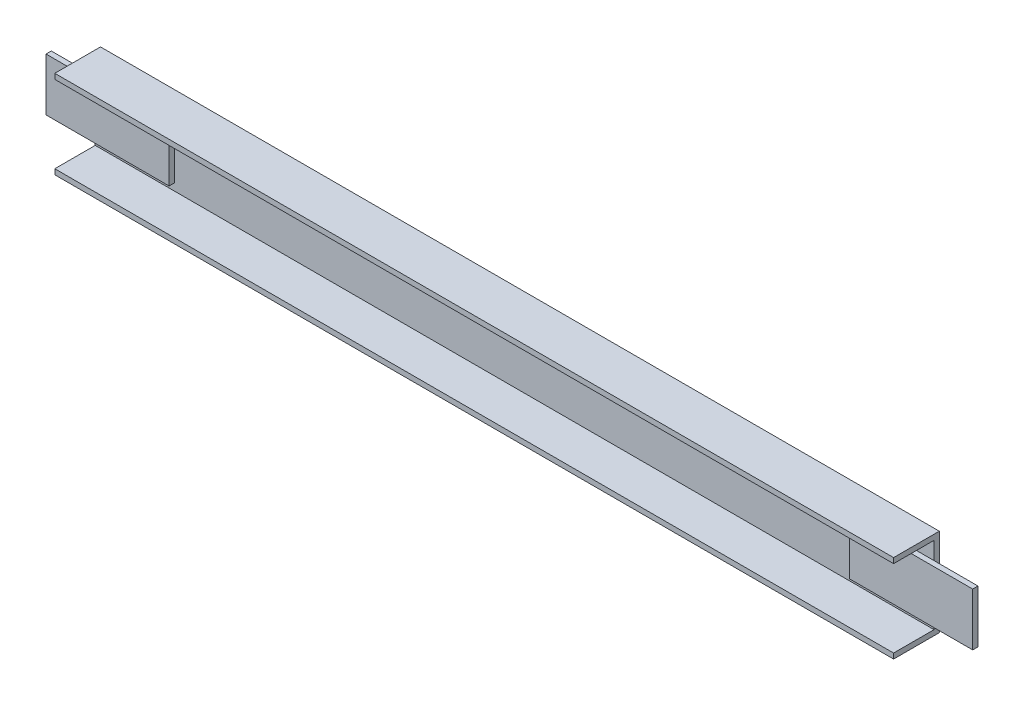
from build123d import *

# Parameters (mm, degrees)
SKETCH1_W           = 477.000009268
SKETCH1_H           = 50.00000447
BOSS_EXTRUDE1_DEPTH = 25.999993086
SKETCH2_W           = 23.000001907
SKETCH2_H           = 43.999992311
CUT_EXTRUDE1_DEPTH  = 722.543490013
SKETCH3_W           = 99.999994039
SKETCH3_H           = 30.000001192
BOSS_EXTRUDE2_DEPTH = 2.999991179
SKETCH4_W           = 99.999995902
SKETCH4_H           = 30.000001192
BOSS_EXTRUDE3_DEPTH = 2.999991179
SKETCH5_W           = 19.999995828
SKETCH5_H           = 19.999995828
BOSS_EXTRUDE4_DEPTH = 10.000020266
MOVE_FACE8_BY       = 30
MOVE_FACE8_2_BY     = 30
MOVE_FACE9_BY       = 5
MOVE_FACE9_2_BY     = 5
MOVE_FACE10_BY      = 5
MOVE_FACE10_2_BY    = 5
MOVE_FACE11_BY      = 2
MOVE_FACE11_2_BY    = 2
MOVE_FACE12_BY      = 2
MOVE_FACE12_2_BY    = 2


with BuildPart() as part:
    # Sketch1 → Boss-Extrude1 (new body)
    with BuildSketch(Plane.XY.offset(513.999998569)):
        with Locations((177.500003949, 144.999999553)):
            Rectangle(SKETCH1_W, SKETCH1_H)
    extrude(amount=-BOSS_EXTRUDE1_DEPTH)

    # Sketch2 → Cut-Extrude1 (cut, through all)
    with BuildSketch(Plane.ZY.offset(61.000000685)):
        with Locations((502.499997616, 144.999999553)):
            Rectangle(SKETCH2_W, SKETCH2_H)
    extrude(amount=-CUT_EXTRUDE1_DEPTH, mode=Mode.SUBTRACT)

    # Sketch3 → Boss-Extrude2 (add)
    with BuildSketch(Plane.XY.offset(490.999996662)):
        with Locations((420.999988914, 144.999995828)):
            Rectangle(SKETCH3_W, SKETCH3_H)
    extrude(amount=BOSS_EXTRUDE2_DEPTH)

    # Sketch4 → Boss-Extrude3 (add)
    with BuildSketch(Plane.XY.offset(490.999996662)):
        with Locations((-65.999998711, 144.999995828)):
            Rectangle(SKETCH4_W, SKETCH4_H)
    extrude(amount=BOSS_EXTRUDE3_DEPTH)

    # Sketch5 → Boss-Extrude4 (add)
    with BuildSketch(Plane(origin=(0, 0, 488.000005484), x_dir=(-1, 0, 0), z_dir=(0, 0, -1))):
        with Locations((-177.500002086, 145.000003278)):
            Rectangle(SKETCH5_W, SKETCH5_H)
    extrude(amount=BOSS_EXTRUDE4_DEPTH)

    # Move Face8: a face moved inward by 30.0
    extrude(part.faces().sort_by_distance((-115.999996662, 144.999995828, 492.499992251))[0], amount=MOVE_FACE8_BY, dir=(1, 0, 0), mode=Mode.SUBTRACT)

    # Move Face8 2: a face moved inward by 30.0
    extrude(part.faces().sort_by_distance((470.999985933, 144.999995828, 492.499992251))[0], amount=MOVE_FACE8_2_BY, dir=(-1, 0, 0), mode=Mode.SUBTRACT)

    # Move Face9: a face moved outward by 5.0
    extrude(part.faces().sort_by_distance((405.999988914, 129.999995232, 492.499992251))[0], amount=MOVE_FACE9_BY, dir=(0, -1, 0))

    # Move Face9 2: a face moved outward by 5.0
    extrude(part.faces().sort_by_distance((-50.999998711, 129.999995232, 492.499992251))[0], amount=MOVE_FACE9_2_BY, dir=(0, -1, 0))

    # Move Face10: a face moved inward by 5.0
    extrude(part.faces().sort_by_distance((-50.999998711, 159.999996424, 492.499992251))[0], amount=MOVE_FACE10_BY, dir=(0, -1, 0), mode=Mode.SUBTRACT)

    # Move Face10 2: a face moved inward by 5.0
    extrude(part.faces().sort_by_distance((405.999988914, 159.999996424, 492.499992251))[0], amount=MOVE_FACE10_2_BY, dir=(0, -1, 0), mode=Mode.SUBTRACT)

    # Move Face11: a face moved outward by 2.0
    extrude(part.faces().sort_by_distance((-50.999998711, 154.999996424, 492.499992251))[0], amount=MOVE_FACE11_BY, dir=(0, 1, 0))

    # Move Face11 2: a face moved outward by 2.0
    extrude(part.faces().sort_by_distance((405.999988914, 154.999996424, 492.499992251))[0], amount=MOVE_FACE11_2_BY, dir=(0, 1, 0))

    # Move Face12: a face moved inward by 2.0
    extrude(part.faces().sort_by_distance((405.999988914, 124.999995232, 492.499992251))[0], amount=MOVE_FACE12_BY, dir=(0, 1, 0), mode=Mode.SUBTRACT)

    # Move Face12 2: a face moved inward by 2.0
    extrude(part.faces().sort_by_distance((-50.999998711, 124.999995232, 492.499992251))[0], amount=MOVE_FACE12_2_BY, dir=(0, 1, 0), mode=Mode.SUBTRACT)


solid = part.part
